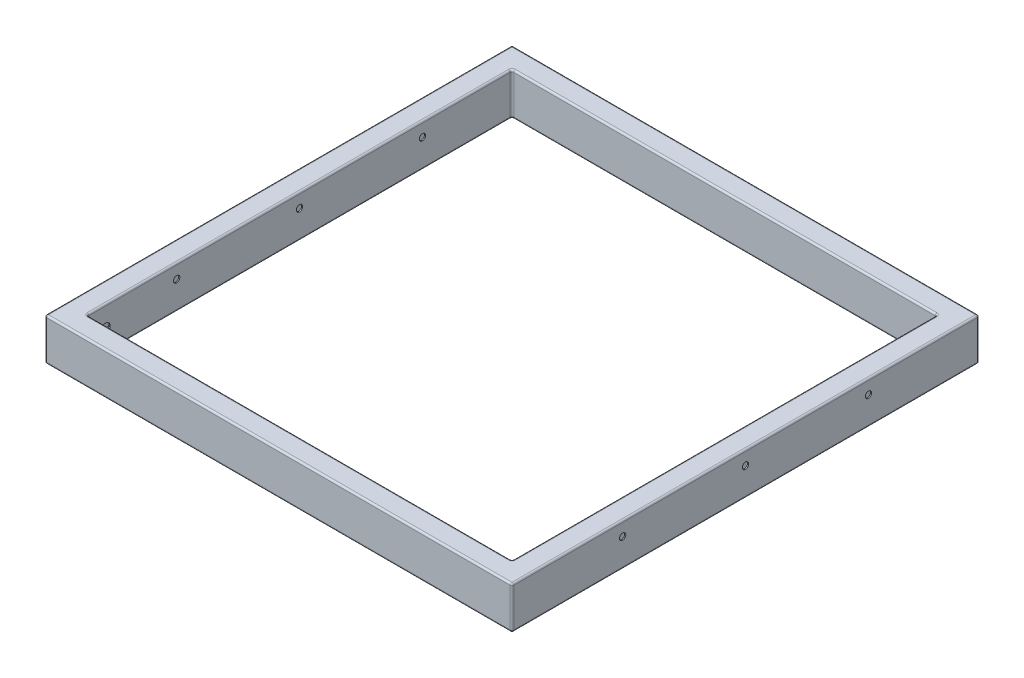
from build123d import *

# Parameters (mm, degrees)
SKETCH1_W           = 1330
SKETCH1_H           = 1330
SKETCH1_W_2         = 1210
SKETCH1_H_2         = 1210
BOSS_EXTRUDE1_DEPTH = 120
FILLET1_R           = 5
SHELL1_T            = 3
SKETCH3_R           = 9
CUT_EXTRUDE1_DEPTH  = 1331
SKETCH4_R           = 13
CUT_EXTRUDE2_DEPTH  = 60


with BuildPart() as part:
    # Sketch1 → Boss-Extrude1 (new body)
    with BuildSketch(Plane(origin=(0, 0, 0), x_dir=(1, 0, 0), z_dir=(0, 1, 0))):
        Rectangle(SKETCH1_W, SKETCH1_H)
        Rectangle(SKETCH1_W_2, SKETCH1_H_2, mode=Mode.SUBTRACT)
    extrude(amount=BOSS_EXTRUDE1_DEPTH)

    # Fillet1
    fillet1_edges = [part.edges().sort_by_distance(p)[0] for p in [
        (-665, 120, 0),
        (0, 120, 665),
        (605, 0, 0),
        (605, 60, 605),
        (0, 0, -605),
        (605, 60, -605),
        (-605, 0, 0),
        (-605, 60, -605),
        (0, 0, 605),
        (-605, 60, 605),
        (605, 120, 0),
        (0, 120, -605),
        (-605, 120, 0),
        (0, 120, 605),
        (665, 120, 0),
        (0, 0, 665),
        (-665, 0, 0),
        (0, 0, -665),
        (665, 0, 0),
        (0, 120, -665),
        (665, 60, 665),
        (-665, 60, 665),
        (-665, 60, -665),
        (665, 60, -665),
    ]]
    fillet(fillet1_edges, radius=FILLET1_R)

    # Shell1 (no face opened: a closed hollow body)
    add(offset(amount=-SHELL1_T, mode=Mode.PRIVATE), mode=Mode.SUBTRACT)

    # Sketch3 → Cut-Extrude1 (cut, through all)
    with BuildSketch(Plane(origin=(665, 0, 0), x_dir=(0, 0, -1), z_dir=(1, 0, 0))):
        with Locations((350, 80)):
            Circle(SKETCH3_R)
        with Locations((0, 80)):
            Circle(SKETCH3_R)
        with Locations((-350, 80)):
            Circle(SKETCH3_R)
    extrude(amount=-CUT_EXTRUDE1_DEPTH, mode=Mode.SUBTRACT)

    # Sketch4 → Cut-Extrude2 (cut)
    with BuildSketch(Plane.ZY.offset(665)):
        with Locations((552.5, 60)):
            Circle(SKETCH4_R)
    extrude(amount=-CUT_EXTRUDE2_DEPTH, mode=Mode.SUBTRACT)


solid = part.part
